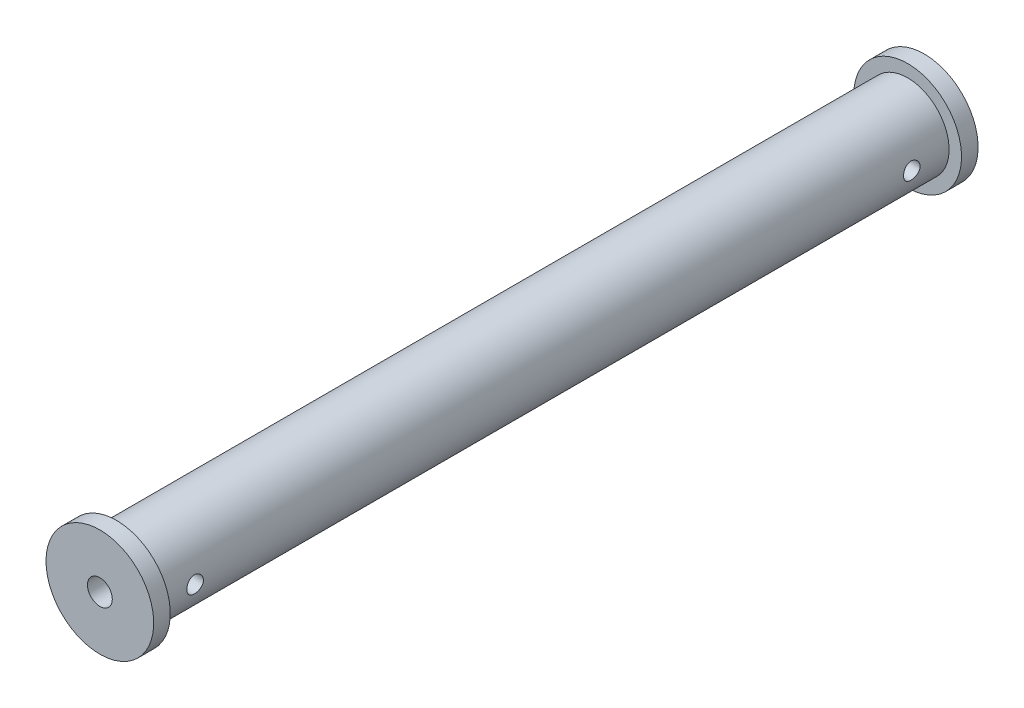
from build123d import *

# Parameters (mm, degrees)
SKETCH1_R                       = 10
SKETCH1_R_2                     = 3
BOSS_EXTRUDE1_DEPTH             = 199
SKETCH2_R                       = 13
SKETCH2_R_2                     = 10
BOSS_EXTRUDE2_DEPTH             = 4
CUT_EXTRUDE1_START              = -25
SKETCH3_W                       = 3
SKETCH3_H                       = 8
CUT_EXTRUDE1_DEPTH              = 47
F_4_0MM_CLEARANCE_DOWEL_HOLE1_D = 4


with BuildPart() as part:
    # Sketch1 → Boss-Extrude1 (new body)
    with BuildSketch(Plane.XY):
        Circle(SKETCH1_R)
        Circle(SKETCH1_R_2, mode=Mode.SUBTRACT)
    extrude(amount=BOSS_EXTRUDE1_DEPTH)

    # Sketch2 → Boss-Extrude2 (add)
    with BuildSketch(Plane(origin=(0, 0, 0), x_dir=(-1, 0, 0), z_dir=(0, 0, -1))):
        Circle(SKETCH2_R)
        Circle(SKETCH2_R_2, mode=Mode.SUBTRACT)
    boss_extrude2 = extrude(amount=-BOSS_EXTRUDE2_DEPTH)

    # Mirror1: Boss-Extrude2 across plane
    add(boss_extrude2.mirror(Plane(origin=(0, 0, 99.5), x_dir=(1, 0, 0), z_dir=(0, 0, -1))))

    # Sketch3 → Cut-Extrude1 (cut)
    with BuildSketch(Plane(origin=(0, 0, 0), x_dir=(1, 0, 0), z_dir=(0, 1, 0)).offset(CUT_EXTRUDE1_START)):
        with Locations((-8.5, -186)):
            Rectangle(SKETCH3_W, SKETCH3_H)
    cut_extrude1 = extrude(amount=CUT_EXTRUDE1_DEPTH, mode=Mode.SUBTRACT)

    # Ø4.0mm Clearance Dowel Hole1 (through all)
    with Locations(Plane(origin=(-7, 0, 186), x_dir=(0, 0, -1), z_dir=(-1, 0, 0))):
        with Locations((0, 0)):
            f_4_0mm_clearance_dowel_hole1 = Hole(F_4_0MM_CLEARANCE_DOWEL_HOLE1_D / 2)

    # Mirror2: Cut-Extrude1, Ø4.0mm Clearance Dowel Hole1 across plane
    add(cut_extrude1.mirror(Plane(origin=(0, 0, 99.5), x_dir=(1, 0, 0), z_dir=(0, 0, -1))), mode=Mode.SUBTRACT)
    add(f_4_0mm_clearance_dowel_hole1.mirror(Plane(origin=(0, 0, 99.5), x_dir=(1, 0, 0), z_dir=(0, 0, -1))), mode=Mode.SUBTRACT)


solid = part.part
